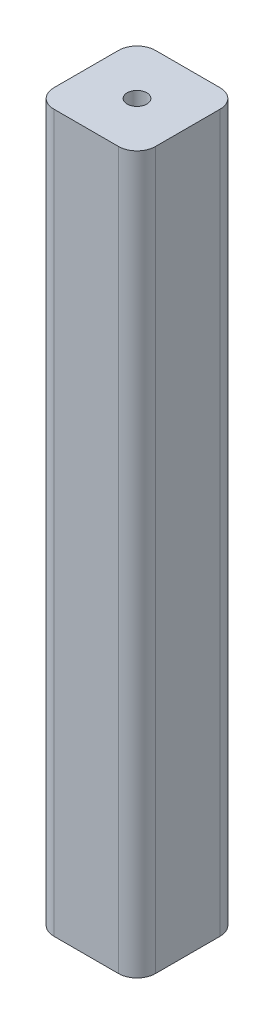
from build123d import *

# Parameters (mm, degrees)
SKETCH_2_W              = 44
SKETCH_2_H              = 44
EXTRUDE_1_DEPTH         = 310
HOLE_WIZARD_M10_1_D     = 8.5
HOLE_WIZARD_M10_1_DEPTH = 25
HOLE_WIZARD_M10_1_TIP   = 2.553657631
HOLE_WIZARD_M6_1_D      = 5
HOLE_WIZARD_M6_1_DEPTH  = 40
HOLE_WIZARD_M6_1_TIP    = 1.502151548
FILLET_1_R              = 8


with BuildPart() as part:
    # 草图2 → 凸台-拉伸1 (new body)
    with BuildSketch(Plane(origin=(0, 0, 0), x_dir=(1, 0, 0), z_dir=(0, 1, 0))):
        with Locations((-0.001355374, -3.30438103)):
            Rectangle(SKETCH_2_W, SKETCH_2_H)
    extrude(amount=EXTRUDE_1_DEPTH)

    # M10 螺纹孔1
    with Locations(Plane(origin=(0, 310, 0), x_dir=(1, 0, 0), z_dir=(0, 1, 0))):
        with Locations((-0.001355374, -3.30438103)):
            Hole(HOLE_WIZARD_M10_1_D / 2, depth=HOLE_WIZARD_M10_1_DEPTH)
            with Locations((0, 0, -(HOLE_WIZARD_M10_1_DEPTH + HOLE_WIZARD_M10_1_TIP / 2))):  # 118° drill point
                Cone(0, HOLE_WIZARD_M10_1_D / 2, HOLE_WIZARD_M10_1_TIP, mode=Mode.SUBTRACT)

    # M6 螺纹孔1
    with Locations(Plane(origin=(-13.001355374, 0, 16.30438103), x_dir=(0, 0, -1), z_dir=(0, -1, 0))):
        with Locations((0, 0), (0, 26), (26, 26), (26, 0)):
            Hole(HOLE_WIZARD_M6_1_D / 2, depth=HOLE_WIZARD_M6_1_DEPTH)
            with Locations((0, 0, -(HOLE_WIZARD_M6_1_DEPTH + HOLE_WIZARD_M6_1_TIP / 2))):  # 118° drill point
                Cone(0, HOLE_WIZARD_M6_1_D / 2, HOLE_WIZARD_M6_1_TIP, mode=Mode.SUBTRACT)

    # 圆角1
    fillet_1_edges = [part.edges().sort_by_distance(p)[0] for p in [
        (-22.001355374, 155, -18.69561897),
        (21.998644626, 155, -18.69561897),
        (21.998644626, 155, 25.30438103),
        (-22.001355374, 155, 25.30438103),
    ]]
    fillet(fillet_1_edges, radius=FILLET_1_R)


solid = part.part
